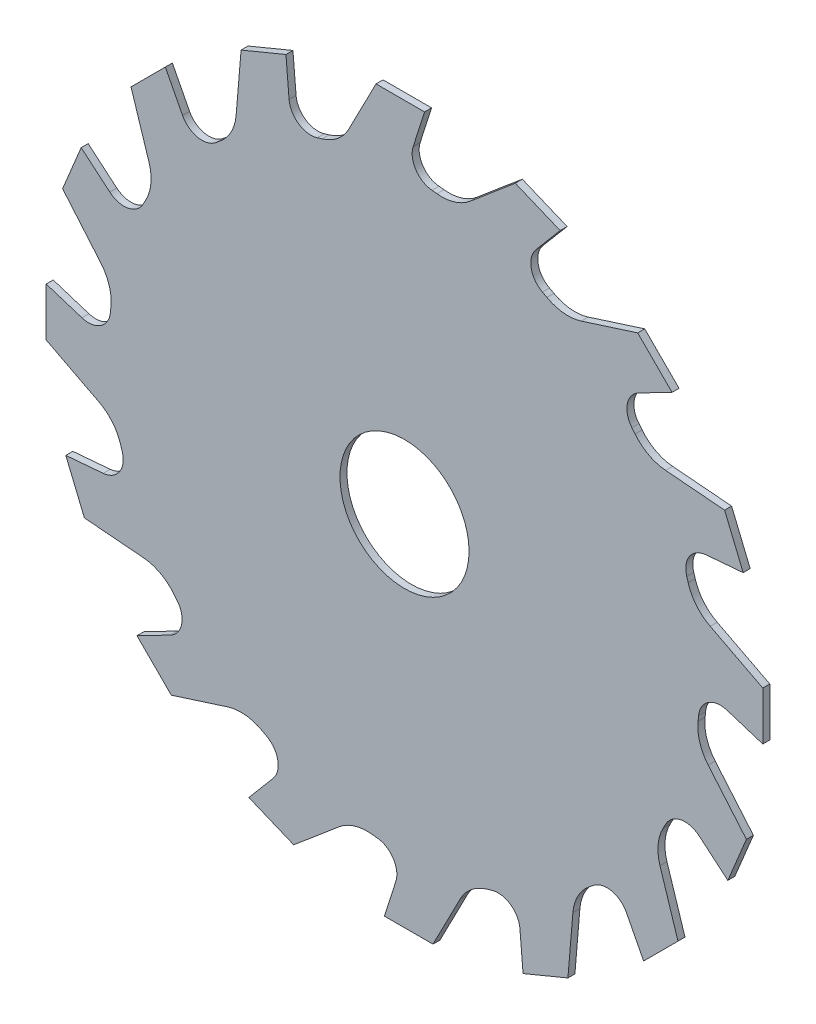
from build123d import *

# Parameters (mm, degrees)
SKETCH1_R           = 7.493
BOSS_EXTRUDE1_DEPTH = 0.8128


with BuildPart() as part:
    # Sketch1 → Boss-Extrude1 (new body)
    with BuildSketch(Plane.XY):
        with BuildLine():
            Line((-6.457079781, 35.480882848), (-3.305892697, 41.587736724))
            Line((-3.305892697, 41.587736724), (2.330830076, 41.587736724))
            Line((2.330830076, 41.587736724), (1.007052256, 37.443040758))
            ThreePointArc((1.007052256, 37.443040758), (1.307937447, 35.269279401), (3.190317281, 34.141264998))
            ThreePointArc((3.190317281, 34.141264998), (3.482262993, 34.112724084), (3.773953868, 34.081686757))
            ThreePointArc((3.773953868, 34.081686757), (5.813520367, 34.271336714), (7.612382182, 35.251078913))
            Line((7.612382182, 35.251078913), (12.860691234, 39.687169127))
            Line((12.860691234, 39.687169127), (18.068344035, 37.530088709))
            Line((18.068344035, 37.530088709), (15.259226323, 34.207476777))
            ThreePointArc((15.259226323, 34.207476777), (14.705345535, 32.084039374), (16.012765313, 30.321534378))
            ThreePointArc((16.012765313, 30.321534378), (16.271565846, 30.183443225), (16.529175604, 30.043143208))
            ThreePointArc((16.529175604, 30.043143208), (18.486065244, 29.437848614), (20.522927965, 29.654617765))
            Line((20.522927965, 29.654617765), (27.069351508, 31.744589796))
            Line((27.069351508, 31.744589796), (31.055116405, 27.758824899))
            Line((31.055116405, 27.758824899), (27.188321507, 25.764134549))
            ThreePointArc((27.188321507, 25.764134549), (25.86399807, 24.014295194), (26.397414982, 21.885625015))
            ThreePointArc((26.397414982, 21.885625015), (26.583670301, 21.659006749), (26.767980192, 21.430803448))
            ThreePointArc((26.767980192, 21.430803448), (28.344274264, 20.122714917), (30.309044005, 19.543509881))
            Line((30.309044005, 19.543509881), (37.156948399, 18.969184434))
            Line((37.156948399, 18.969184434), (39.314028817, 13.761531633))
            Line((39.314028817, 13.761531633), (34.978241205, 13.398436388))
            ThreePointArc((34.978241205, 13.398436388), (33.085091357, 12.288592261), (32.763297513, 10.117827636))
            ThreePointArc((32.763297513, 10.117827636), (32.848651934, 9.837182834), (32.931602448, 9.555818134))
            ThreePointArc((32.931602448, 9.555818134), (33.88732447, 7.744080287), (35.480882848, 6.457079781))
            Line((35.480882848, 6.457079781), (41.587736724, 3.305892697))
            Line((41.587736724, 3.305892697), (41.587736724, -2.330830076))
            Line((41.587736724, -2.330830076), (37.443040758, -1.007052256))
            ThreePointArc((37.443040758, -1.007052256), (35.269279401, -1.307937447), (34.141264998, -3.190317281))
            ThreePointArc((34.141264998, -3.190317281), (34.112724084, -3.482262993), (34.081686757, -3.773953868))
            ThreePointArc((34.081686757, -3.773953868), (34.271336714, -5.813520367), (35.251078913, -7.612382182))
            Line((35.251078913, -7.612382182), (39.687169127, -12.860691234))
            Line((39.687169127, -12.860691234), (37.530088709, -18.068344035))
            Line((37.530088709, -18.068344035), (34.207476777, -15.259226323))
            ThreePointArc((34.207476777, -15.259226323), (32.084039374, -14.705345535), (30.321534378, -16.012765313))
            ThreePointArc((30.321534378, -16.012765313), (30.183443225, -16.271565846), (30.043143208, -16.529175604))
            ThreePointArc((30.043143208, -16.529175604), (29.437848614, -18.486065244), (29.654617765, -20.522927965))
            Line((29.654617765, -20.522927965), (31.744589796, -27.069351508))
            Line((31.744589796, -27.069351508), (27.758824899, -31.055116405))
            Line((27.758824899, -31.055116405), (25.764134549, -27.188321507))
            ThreePointArc((25.764134549, -27.188321507), (24.014295194, -25.86399807), (21.885625015, -26.397414982))
            ThreePointArc((21.885625015, -26.397414982), (21.659006749, -26.583670301), (21.430803448, -26.767980192))
            ThreePointArc((21.430803448, -26.767980192), (20.122714917, -28.344274264), (19.543509881, -30.309044005))
            Line((19.543509881, -30.309044005), (18.969184434, -37.156948399))
            Line((18.969184434, -37.156948399), (13.761531633, -39.314028817))
            Line((13.761531633, -39.314028817), (13.398436388, -34.978241205))
            ThreePointArc((13.398436388, -34.978241205), (12.288592261, -33.085091357), (10.117827636, -32.763297513))
            ThreePointArc((10.117827636, -32.763297513), (9.837182834, -32.848651934), (9.555818134, -32.931602448))
            ThreePointArc((9.555818134, -32.931602448), (7.744080287, -33.88732447), (6.457079781, -35.480882848))
            Line((6.457079781, -35.480882848), (3.305892697, -41.587736724))
            Line((3.305892697, -41.587736724), (-2.330830076, -41.587736724))
            Line((-2.330830076, -41.587736724), (-1.007052256, -37.443040758))
            ThreePointArc((-1.007052256, -37.443040758), (-1.307937447, -35.269279401), (-3.190317281, -34.141264998))
            ThreePointArc((-3.190317281, -34.141264998), (-3.482262993, -34.112724084), (-3.773953868, -34.081686757))
            ThreePointArc((-3.773953868, -34.081686757), (-5.813520367, -34.271336714), (-7.612382182, -35.251078913))
            Line((-7.612382182, -35.251078913), (-12.860691234, -39.687169127))
            Line((-12.860691234, -39.687169127), (-18.068344035, -37.530088709))
            Line((-18.068344035, -37.530088709), (-15.259226323, -34.207476777))
            ThreePointArc((-15.259226323, -34.207476777), (-14.705345535, -32.084039374), (-16.012765313, -30.321534378))
            ThreePointArc((-16.012765313, -30.321534378), (-16.271565846, -30.183443225), (-16.529175604, -30.043143208))
            ThreePointArc((-16.529175604, -30.043143208), (-18.486065244, -29.437848614), (-20.522927965, -29.654617765))
            Line((-20.522927965, -29.654617765), (-27.069351508, -31.744589796))
            Line((-27.069351508, -31.744589796), (-31.055116405, -27.758824899))
            Line((-31.055116405, -27.758824899), (-27.188321507, -25.764134549))
            ThreePointArc((-27.188321507, -25.764134549), (-25.86399807, -24.014295194), (-26.397414982, -21.885625015))
            ThreePointArc((-26.397414982, -21.885625015), (-26.583670301, -21.659006749), (-26.767980192, -21.430803448))
            ThreePointArc((-26.767980192, -21.430803448), (-28.344274264, -20.122714917), (-30.309044005, -19.543509881))
            Line((-30.309044005, -19.543509881), (-37.156948399, -18.969184434))
            Line((-37.156948399, -18.969184434), (-39.314028817, -13.761531633))
            Line((-39.314028817, -13.761531633), (-34.978241205, -13.398436388))
            ThreePointArc((-34.978241205, -13.398436388), (-33.085091357, -12.288592261), (-32.763297513, -10.117827636))
            ThreePointArc((-32.763297513, -10.117827636), (-32.848651934, -9.837182834), (-32.931602448, -9.555818134))
            ThreePointArc((-32.931602448, -9.555818134), (-33.88732447, -7.744080287), (-35.480882848, -6.457079781))
            Line((-35.480882848, -6.457079781), (-41.587736724, -3.305892697))
            Line((-41.587736724, -3.305892697), (-41.587736724, 2.330830076))
            Line((-41.587736724, 2.330830076), (-37.443040758, 1.007052256))
            ThreePointArc((-37.443040758, 1.007052256), (-35.269279401, 1.307937447), (-34.141264998, 3.190317281))
            ThreePointArc((-34.141264998, 3.190317281), (-34.112724084, 3.482262993), (-34.081686757, 3.773953868))
            ThreePointArc((-34.081686757, 3.773953868), (-34.271336714, 5.813520367), (-35.251078913, 7.612382182))
            Line((-35.251078913, 7.612382182), (-39.687169127, 12.860691234))
            Line((-39.687169127, 12.860691234), (-37.530088709, 18.068344035))
            Line((-37.530088709, 18.068344035), (-34.207476777, 15.259226323))
            ThreePointArc((-34.207476777, 15.259226323), (-32.084039374, 14.705345535), (-30.321534378, 16.012765313))
            ThreePointArc((-30.321534378, 16.012765313), (-30.183443225, 16.271565846), (-30.043143208, 16.529175604))
            ThreePointArc((-30.043143208, 16.529175604), (-29.437848614, 18.486065244), (-29.654617765, 20.522927965))
            Line((-29.654617765, 20.522927965), (-31.744589796, 27.069351508))
            Line((-31.744589796, 27.069351508), (-27.758824899, 31.055116405))
            Line((-27.758824899, 31.055116405), (-25.764134549, 27.188321507))
            ThreePointArc((-25.764134549, 27.188321507), (-24.014295194, 25.86399807), (-21.885625015, 26.397414982))
            ThreePointArc((-21.885625015, 26.397414982), (-21.659006749, 26.583670301), (-21.430803448, 26.767980192))
            ThreePointArc((-21.430803448, 26.767980192), (-20.122714917, 28.344274264), (-19.543509881, 30.309044005))
            Line((-19.543509881, 30.309044005), (-18.969184434, 37.156948399))
            Line((-18.969184434, 37.156948399), (-13.761531633, 39.314028817))
            Line((-13.761531633, 39.314028817), (-13.398436388, 34.978241205))
            ThreePointArc((-13.398436388, 34.978241205), (-12.288592261, 33.085091357), (-10.117827636, 32.763297513))
            ThreePointArc((-10.117827636, 32.763297513), (-9.837182834, 32.848651934), (-9.555818134, 32.931602448))
            ThreePointArc((-9.555818134, 32.931602448), (-7.744080287, 33.88732447), (-6.457079781, 35.480882848))
        make_face()
        Circle(SKETCH1_R, mode=Mode.SUBTRACT)
    extrude(amount=BOSS_EXTRUDE1_DEPTH)


solid = part.part
